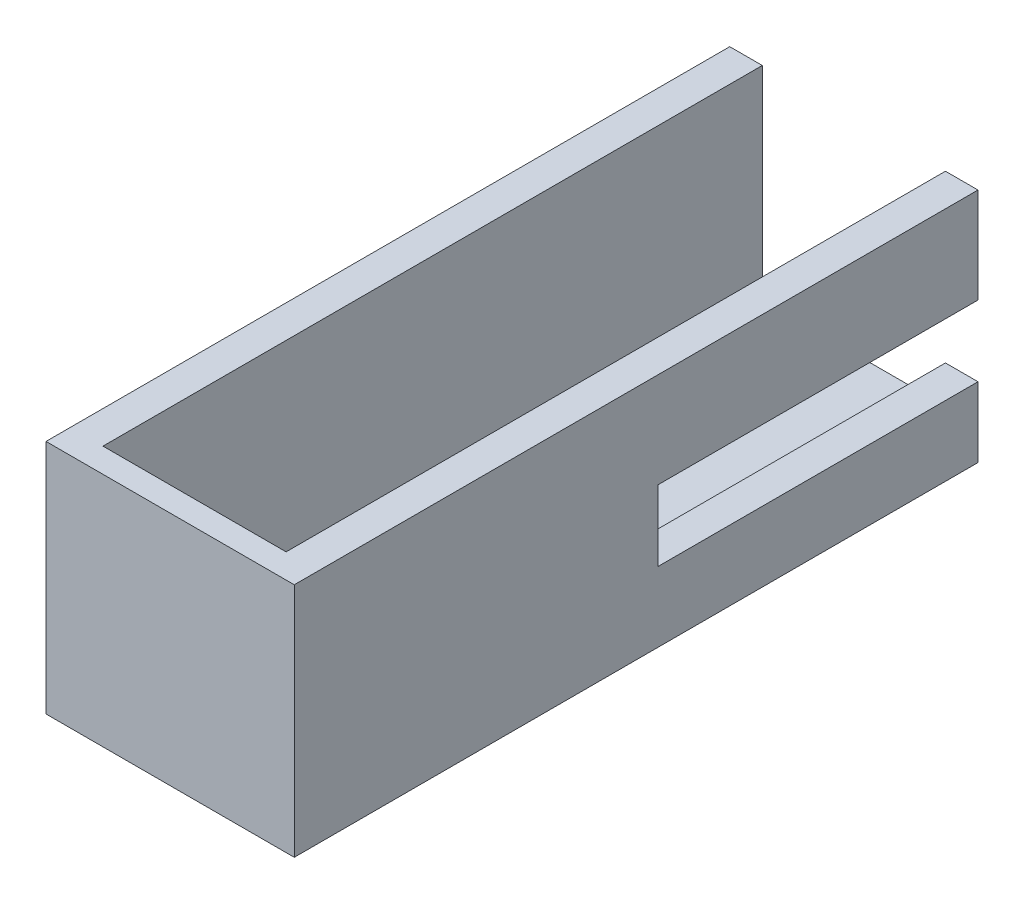
from build123d import *

# Parameters (mm, degrees)
BOSS_EXTRUDE1_DEPTH = 42
SKETCH2_W           = 30.5
SKETCH2_H           = 29
BOSS_EXTRUDE2_DEPTH = 3
SKETCH3_W           = 40
SKETCH3_H           = 8.69
CUT_EXTRUDE1_DEPTH  = 30


with BuildPart() as part:
    # Sketch1 → Boss-Extrude1 (new body, symmetric)
    with BuildSketch(Plane.XY):
        Polygon((-9.848648649, 0), (-9.848648649, -25), (12.651351351, -25), (12.651351351, 0), (16.651351351, 0), (16.651351351, -29), (-13.848648649, -29), (-13.848648649, 0), align=None)
    extrude(amount=BOSS_EXTRUDE1_DEPTH, both=True)

    # Sketch2 → Boss-Extrude2 (add)
    with BuildSketch(Plane.XY.offset(42)):
        with Locations((1.401351351, -14.5)):
            Rectangle(SKETCH2_W, SKETCH2_H)
    extrude(amount=-BOSS_EXTRUDE2_DEPTH)

    # Sketch3 → Cut-Extrude1 (cut)
    with BuildSketch(Plane(origin=(0, 0, 0), x_dir=(0, 0, -1), z_dir=(1, 0, 0))):
        with Locations((22.65905185, -16.052995557)):
            Rectangle(SKETCH3_W, SKETCH3_H)
    extrude(amount=CUT_EXTRUDE1_DEPTH, mode=Mode.SUBTRACT)


solid = part.part
